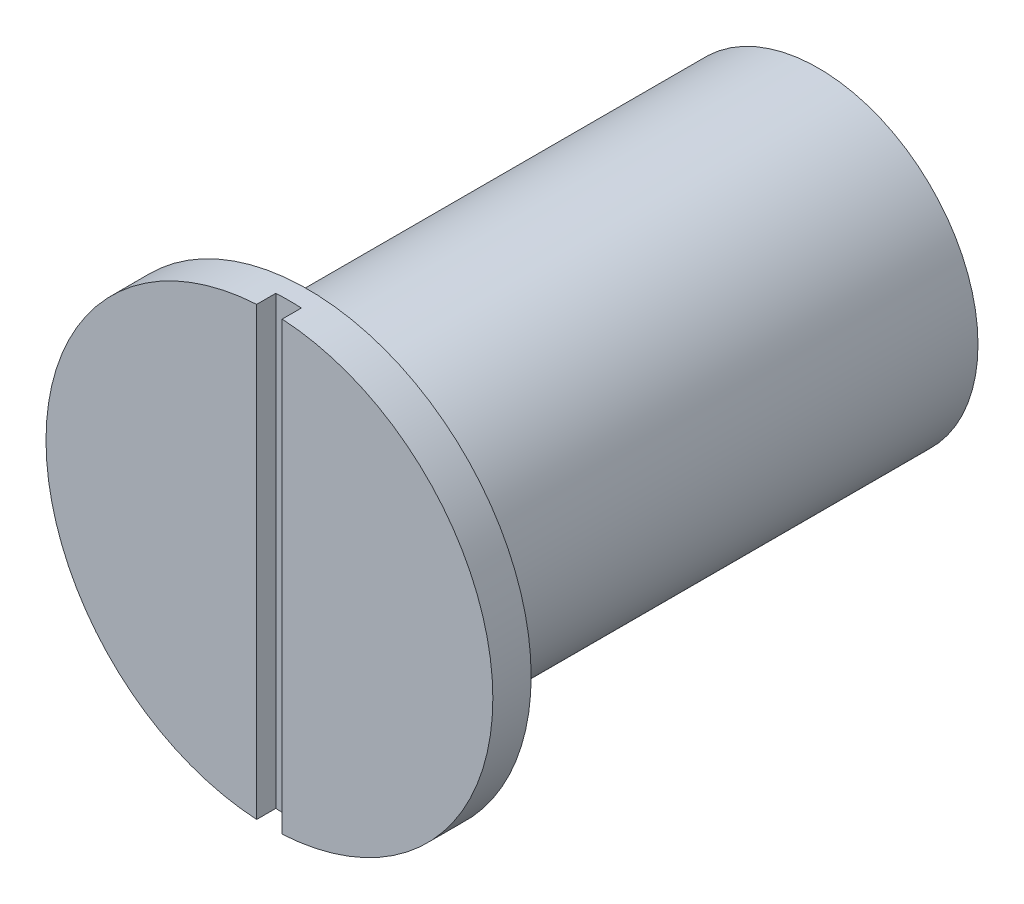
from build123d import *

# Parameters (mm, degrees)
CROQUIS1_R              = 1.75
SALIENTE_EXTRUIR1_DEPTH = 0.3
CORTAR_EXTRUIR1_DEPTH   = 0.15
CROQUIS3_R              = 1.25
SALIENTE_EXTRUIR2_DEPTH = 4
REDONDEO1_R             = 0.1


with BuildPart() as part:
    # Croquis1 → Saliente-Extruir1 (new body)
    with BuildSketch(Plane.XY):
        Circle(CROQUIS1_R)
    extrude(amount=SALIENTE_EXTRUIR1_DEPTH)

    # Croquis2 → Cortar-Extruir1 (cut)
    with BuildSketch(Plane.XY.offset(0.3)):
        with BuildLine():
            Line((0.1, 1.747140521), (0.1, -1.747140521))
            ThreePointArc((0.1, -1.747140521), (0, -1.75), (-0.1, -1.747140521))
            Line((-0.1, -1.747140521), (-0.1, 1.747140521))
            ThreePointArc((-0.1, 1.747140521), (0, 1.75), (0.1, 1.747140521))
        make_face()
    extrude(amount=-CORTAR_EXTRUIR1_DEPTH, mode=Mode.SUBTRACT)

    # Croquis3 → Saliente-Extruir2 (add)
    with BuildSketch(Plane(origin=(0, 0, 0), x_dir=(-1, 0, 0), z_dir=(0, 0, -1))):
        Circle(CROQUIS3_R)
    extrude(amount=SALIENTE_EXTRUIR2_DEPTH)

    # Redondeo1
    redondeo1_edges = [part.edges().sort_by_distance(p)[0] for p in [
        (1.25, 0, 0),
    ]]
    fillet(redondeo1_edges, radius=REDONDEO1_R)


solid = part.part
